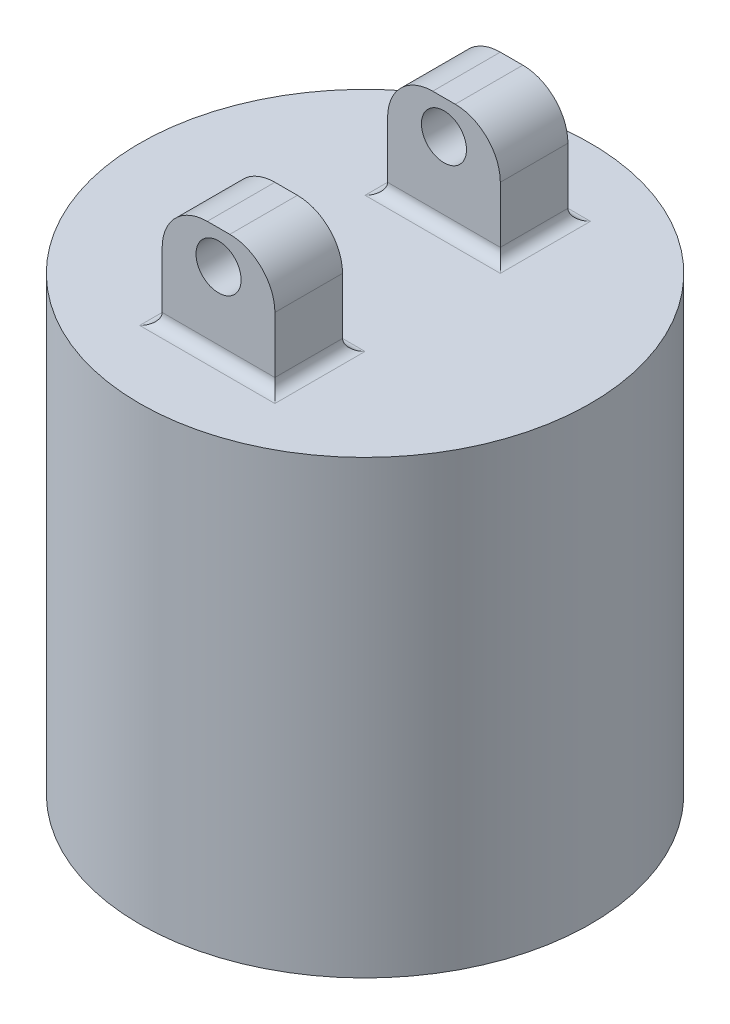
from build123d import *

# Parameters (mm, degrees)
SKETCH1_R                = 50
BOSS_EXTRUDE1_DEPTH      = 100
SKETCH2_W                = 25
SKETCH2_H                = 15
BOSS_EXTRUDE2_DEPTH      = 25
FILLET1_R                = 2.5
FILLET2_R                = 10
SKETCH3_R                = 5
CUT_EXTRUDE1_DEPTH       = 25
CIRPATTERN1_COUNT        = 2
FILLET1_OF_CIRPATTERN1_R = 2.5
FILLET2_OF_CIRPATTERN1_R = 10


with BuildPart() as part:
    # Sketch1 → Boss-Extrude1 (new body)
    with BuildSketch(Plane(origin=(0, 0, 0), x_dir=(1, 0, 0), z_dir=(0, 1, 0))):
        Circle(SKETCH1_R)
    extrude(amount=BOSS_EXTRUDE1_DEPTH)

    # Sketch2 → Boss-Extrude2 (add)
    with BuildSketch(Plane(origin=(0, 100, 0), x_dir=(1, 0, 0), z_dir=(0, 1, 0))):
        with Locations((0, -25)):
            Rectangle(SKETCH2_W, SKETCH2_H)
    boss_extrude2 = extrude(amount=BOSS_EXTRUDE2_DEPTH)

    # Fillet1
    fillet1_edges = [part.edges().sort_by_distance(p)[0] for p in [
        (12.5, 100, 25),
        (0, 100, 17.5),
        (-12.5, 100, 25),
        (0, 100, 32.5),
    ]]
    fillet(fillet1_edges, radius=FILLET1_R)

    # Fillet2
    fillet2_edges = [part.edges().sort_by_distance(p)[0] for p in [
        (12.5, 125, 25),
        (-12.5, 125, 25),
    ]]
    fillet(fillet2_edges, radius=FILLET2_R)

    # Sketch3 → Cut-Extrude1 (cut)
    with BuildSketch(Plane.XY.offset(32.5)):
        with Locations((0, 117.5)):
            Circle(SKETCH3_R)
    cut_extrude1 = extrude(amount=-CUT_EXTRUDE1_DEPTH, mode=Mode.SUBTRACT)

    # CirPattern1: Boss-Extrude2, Cut-Extrude1 ×2 about axis
    cirpattern1_axis = Axis((0, 0, 0), (0, 1, 0))
    for i in range(1, CIRPATTERN1_COUNT):
        add(boss_extrude2.rotate(cirpattern1_axis, i * 360 / CIRPATTERN1_COUNT))
        add(cut_extrude1.rotate(cirpattern1_axis, i * 360 / CIRPATTERN1_COUNT), mode=Mode.SUBTRACT)

    # Fillet1 of CirPattern1
    fillet1_of_cirpattern1_edges = [part.edges().sort_by_distance(p)[0] for p in [
        (-12.5, 100, -25),
        (0, 100, -17.5),
        (12.5, 100, -25),
        (0, 100, -32.5),
    ]]
    fillet(fillet1_of_cirpattern1_edges, radius=FILLET1_OF_CIRPATTERN1_R)

    # Fillet2 of CirPattern1
    fillet2_of_cirpattern1_edges = [part.edges().sort_by_distance(p)[0] for p in [
        (-12.5, 125, -25),
        (12.5, 125, -25),
    ]]
    fillet(fillet2_of_cirpattern1_edges, radius=FILLET2_OF_CIRPATTERN1_R)


solid = part.part
